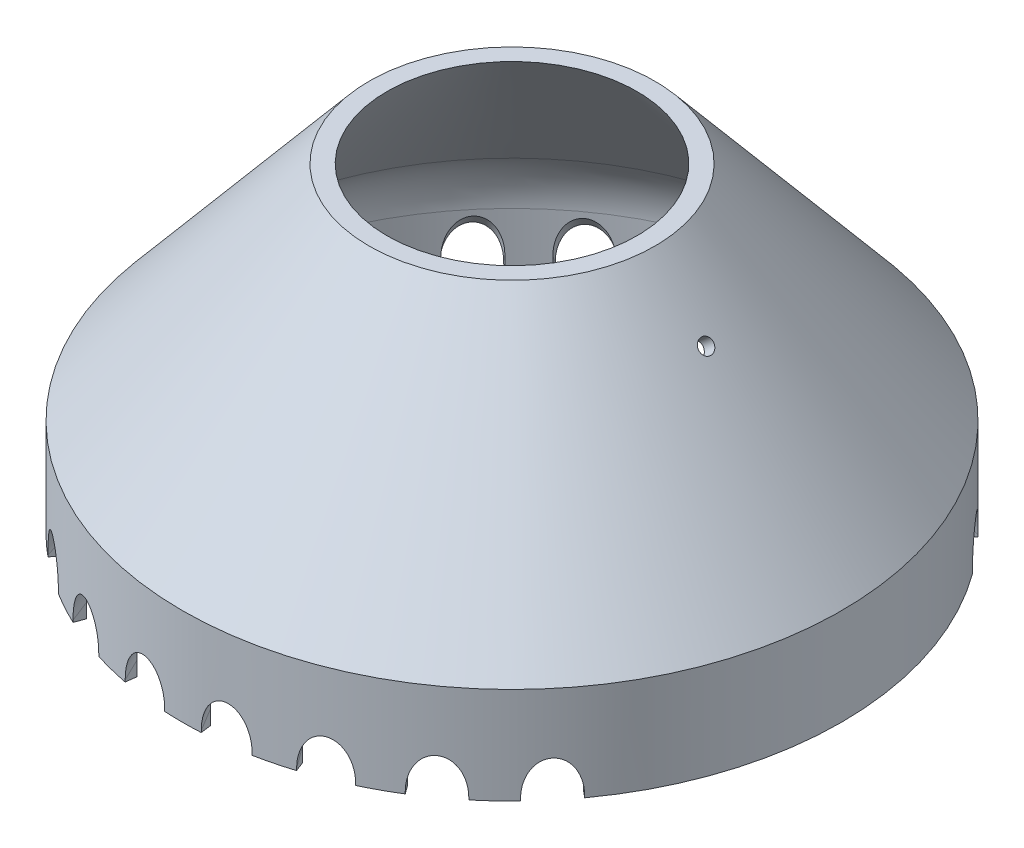
from build123d import *

# Parameters (mm, degrees)
SUPPORT_START                    = -0.012368
SKETCH4_R                        = 0.80645
SUPPORT_HOLE_1_DEPTH             = 1.512368
SUPPORT_HOLE_2_REACH             = 72.738
SKETCH3_R                        = 0.80645
SUPPORT_HOLE_2_DIRECTION_2_REACH = 72.738
TURN_TOOL_CHANNEL_REACH          = 67.392
CRVPATTERN2_COUNT                = 8
CRVPATTERN2_ANGLE                = 100
MIRROR1_COPY_1_REACH             = 67.392
MIRROR1_COPY_2_REACH             = 67.392
MIRROR1_COPY_3_REACH             = 67.392
MIRROR1_COPY_4_REACH             = 67.392
MIRROR1_COPY_5_REACH             = 67.392
MIRROR1_COPY_6_REACH             = 67.392
MIRROR1_COPY_7_REACH             = 67.392


with BuildPart() as part:
    # Cone Cross Section → Revolve1 (revolve)
    with BuildSketch(Plane(origin=(0, 0, 0), x_dir=(1, 0, 0), z_dir=(0, 0, -1)), mode=Mode.PRIVATE) as revolve1_sk:
        with BuildLine():
            Line((13.718550028, 0), (32.660444431, 22.574070706))
            ThreePointArc((32.660444431, 22.574070706), (34.396926208, 25.581745369), (35, 29.001946803))
            Line((35, 29.001946803), (35, 35))
            Line((35, 35), (36.149066665, 35))
            Line((36.149066665, 35), (36.149066665, 24.398063045))
            Line((36.149066665, 24.398063045), (15.676660962, 0))
            Line((15.676660962, 0), (13.718550028, 0))
        make_face()
    revolve(revolve1_sk.sketch.rotate(Axis((0, 0, 0), (0, -1, 0)), 90), axis=Axis((0, 0, 0), (0, -1, 0)))

    # Sketch4 → Support Hole 1 (cut)
    with BuildSketch(Plane(origin=(-8.05037562, 6.755067214, 0), x_dir=(0, 0, 1), z_dir=(-0.766044443118977, 0.6427876096865406, 0)).offset(SUPPORT_START)):
        with Locations(Location((0, -18.818113981, 0), (0, 0, 222.025362507))):
            Circle(SKETCH4_R)
    extrude(amount=SUPPORT_HOLE_1_DEPTH, mode=Mode.SUBTRACT)

    # Support Hole 2: up to this cone (the profile starts outside it)
    support_hole_2_end = Plane(origin=(0, -7.660444, 0), z_dir=(0, -1, 0)).offset(-24.009574281) * Cone(1e-06, 98.505262978, 117.394000044, align=(Align.CENTER, Align.CENTER, Align.MIN), mode=Mode.PRIVATE)
    # Sketch3 → Support Hole 2 (cut, up to the surface)
    with BuildSketch(Plane(origin=(8.05037562, 6.755067214, 0), x_dir=(0, 0, 1), z_dir=(-0.766044443118977, -0.6427876096865406, 0)), mode=Mode.PRIVATE) as support_hole_2_sk1:
        with Locations(Location((0, -18.818113981, 0), (0, 0, 222.025362507))):
            Circle(SKETCH3_R)
    support_hole_2_tool1 = extrude(support_hole_2_sk1.sketch, amount=SUPPORT_HOLE_2_REACH, mode=Mode.PRIVATE) - support_hole_2_end
    add(support_hole_2_tool1.solids().sort_by_distance((20.146426, -7.660444, 0))[0], mode=Mode.SUBTRACT)

    # Support Hole 2 direction 2: up to this cone (the profile starts inside it)
    support_hole_2_direction_2_end = Plane(origin=(0, -7.660444, 0), z_dir=(0, -1, 0)).offset(-26.343160021) * Cone(1e-06, 102.106424075, 121.685696718, align=(Align.CENTER, Align.CENTER, Align.MIN), mode=Mode.PRIVATE)
    # Sketch3 → Support Hole 2 direction 2 (cut, up to the surface)
    with BuildSketch(Plane(origin=(8.05037562, 6.755067214, 0), x_dir=(0, 0, 1), z_dir=(-0.766044443118977, -0.6427876096865406, 0)), mode=Mode.PRIVATE) as support_hole_2_direction_2_sk1:
        with Locations(Location((0, -18.818113981, 0), (0, 0, 222.025362507))):
            Circle(SKETCH3_R)
    support_hole_2_direction_2_tool1 = extrude(support_hole_2_direction_2_sk1.sketch, amount=-SUPPORT_HOLE_2_DIRECTION_2_REACH, mode=Mode.PRIVATE) & support_hole_2_direction_2_end
    add(support_hole_2_direction_2_tool1.solids().sort_by_distance((20.146426, -7.660444, 0))[0], mode=Mode.SUBTRACT)


with BuildPart() as support_hole_2_kept_piece:
    # of the separate pieces the step leaves, the one the design keeps (support_hole_2_pieces_kept)
    add(part.part.solids().sort_by_distance((0, 0, 13.718550028))[0])

    # Sketch5 → Turn Tool Channel (cut, up to next)
    with BuildSketch(Plane(origin=(7.788900643, -12.117378316, 6.535663657), x_dir=(0.8703668320896414, 0.43338422313512226, -0.2337513480940991), z_dir=(-0.4924038765061076, 0.7660444431189767, -0.413175911166533)), mode=Mode.PRIVATE) as turn_tool_channel_sk1:
        with BuildLine():
            Line((1.699455866, -5.569482092), (-1.671674945, -1.876857408))
            Line((-1.671674945, -1.876857408), (2.020949739, 1.494273403))
            Line((2.020949739, 1.494273403), (5.39208055, -2.198351282))
            ThreePointArc((5.39208055, -2.198351282), (5.231333613, -5.730229029), (1.699455866, -5.569482092))
        make_face()
    turn_tool_channel_tool1 = extrude(turn_tool_channel_sk1.sketch, amount=-TURN_TOOL_CHANNEL_REACH, mode=Mode.PRIVATE) & support_hole_2_kept_piece.part
    turn_tool_channel = turn_tool_channel_tool1.solids().sort_by_distance((9.997192, -9.69849, 8.38864))[0]
    add(turn_tool_channel, mode=Mode.SUBTRACT)

    # CrvPattern2: Turn Tool Channel ×8 about axis
    crvpattern2_axis = Axis((0, -10.826005784, 0), (0, -1, 0))
    for i in range(1, CRVPATTERN2_COUNT):
        add(turn_tool_channel.rotate(crvpattern2_axis, i * CRVPATTERN2_ANGLE / (CRVPATTERN2_COUNT - 1)), mode=Mode.SUBTRACT)

    # Mirror1: Turn Tool Channel across plane
    add(turn_tool_channel.mirror(Plane.XY), mode=Mode.SUBTRACT)

    # Mirror1 copy 1 sketch → Mirror1 copy 1 (cut, up to next)
    with BuildSketch(Plane(origin=(5.935323342, -12.117378316, -8.255532054), x_dir=(0.9011326020275271, 0.43338422313512226, 0.011753667541032992), z_dir=(-0.37522319974544693, 0.7660444431189767, 0.5219036899077504)), mode=Mode.PRIVATE) as mirror1_copy_1_sk1:
        with BuildLine():
            Line((1.699455866, 5.569482092), (-1.671674945, 1.876857408))
            Line((-1.671674945, 1.876857408), (2.020949739, -1.494273403))
            Line((2.020949739, -1.494273403), (5.39208055, 2.198351282))
            ThreePointArc((5.39208055, 2.198351282), (5.231333613, 5.730229029), (1.699455866, 5.569482092))
        make_face()
    mirror1_copy_1_tool1 = extrude(mirror1_copy_1_sk1.sketch, amount=-MIRROR1_COPY_1_REACH, mode=Mode.PRIVATE) & support_hole_2_kept_piece.part
    add(mirror1_copy_1_tool1.solids().sort_by_distance((7.618092717, -9.69849, -10.596121568))[0], mode=Mode.SUBTRACT)

    # Mirror1 copy 2 sketch → Mirror1 copy 2 (cut, up to next)
    with BuildSketch(Plane(origin=(3.714673431, -12.117378316, -9.464833541), x_dir=(0.8761674409211258, 0.43338422313512226, -0.21097092360629302), z_dir=(-0.2348366837729102, 0.7660444431189767, 0.5983541118109569)), mode=Mode.PRIVATE) as mirror1_copy_2_sk1:
        with BuildLine():
            Line((1.699455866, 5.569482092), (-1.671674945, 1.876857408))
            Line((-1.671674945, 1.876857408), (2.020949739, -1.494273403))
            Line((2.020949739, -1.494273403), (5.39208055, 2.198351282))
            ThreePointArc((5.39208055, 2.198351282), (5.231333613, 5.730229029), (1.699455866, 5.569482092))
        make_face()
    mirror1_copy_2_tool1 = extrude(mirror1_copy_2_sk1.sketch, amount=-MIRROR1_COPY_2_REACH, mode=Mode.PRIVATE) & support_hole_2_kept_piece.part
    add(mirror1_copy_2_tool1.solids().sort_by_distance((4.767849232, -9.69849, -12.148281468))[0], mode=Mode.SUBTRACT)

    # Mirror1 copy 3 sketch → Mirror1 copy 3 (cut, up to next)
    with BuildSketch(Plane(origin=(1.264287953, -12.117378316, -10.088778352), x_dir=(0.7970153298327136, 0.43338422313512226, -0.42064792778429017), z_dir=(-0.07992659268992885, 0.7660444431189767, 0.637799067847794)), mode=Mode.PRIVATE) as mirror1_copy_3_sk1:
        with BuildLine():
            Line((1.699455866, 5.569482092), (-1.671674945, 1.876857408))
            Line((-1.671674945, 1.876857408), (2.020949739, -1.494273403))
            Line((2.020949739, -1.494273403), (5.39208055, 2.198351282))
            ThreePointArc((5.39208055, 2.198351282), (5.231333613, 5.730229029), (1.699455866, 5.569482092))
        make_face()
    mirror1_copy_3_tool1 = extrude(mirror1_copy_3_sk1.sketch, amount=-MIRROR1_COPY_3_REACH, mode=Mode.PRIVATE) & support_hole_2_kept_piece.part
    add(mirror1_copy_3_tool1.solids().sort_by_distance((1.622736074, -9.69849, -12.949125707))[0], mode=Mode.SUBTRACT)

    # Mirror1 copy 4 sketch → Mirror1 copy 4 (cut, up to next)
    with BuildSketch(Plane(origin=(-1.264287953, -12.117378316, -10.088778352), x_dir=(0.6685714649133934, 0.43338422313512226, -0.6043097810238768), z_dir=(0.07992659268992386, 0.7660444431189767, 0.6377990678477947)), mode=Mode.PRIVATE) as mirror1_copy_4_sk1:
        with BuildLine():
            Line((1.699455866, 5.569482092), (-1.671674945, 1.876857408))
            Line((-1.671674945, 1.876857408), (2.020949739, -1.494273403))
            Line((2.020949739, -1.494273403), (5.39208055, 2.198351282))
            ThreePointArc((5.39208055, 2.198351282), (5.231333613, 5.730229029), (1.699455866, 5.569482092))
        make_face()
    mirror1_copy_4_tool1 = extrude(mirror1_copy_4_sk1.sketch, amount=-MIRROR1_COPY_4_REACH, mode=Mode.PRIVATE) & support_hole_2_kept_piece.part
    add(mirror1_copy_4_tool1.solids().sort_by_distance((-1.622735891, -9.69849, -12.94912573))[0], mode=Mode.SUBTRACT)

    # Mirror1 copy 5 sketch → Mirror1 copy 5 (cut, up to next)
    with BuildSketch(Plane(origin=(-3.714673431, -12.117378316, -9.464833541), x_dir=(0.4987795119042271, 0.43338422313512226, -0.7505978374883235), z_dir=(0.23483668377290537, 0.7660444431189767, 0.5983541118109588)), mode=Mode.PRIVATE) as mirror1_copy_5_sk1:
        with BuildLine():
            Line((1.699455866, 5.569482092), (-1.671674945, 1.876857408))
            Line((-1.671674945, 1.876857408), (2.020949739, -1.494273403))
            Line((2.020949739, -1.494273403), (5.39208055, 2.198351282))
            ThreePointArc((5.39208055, 2.198351282), (5.231333613, 5.730229029), (1.699455866, 5.569482092))
        make_face()
    mirror1_copy_5_tool1 = extrude(mirror1_copy_5_sk1.sketch, amount=-MIRROR1_COPY_5_REACH, mode=Mode.PRIVATE) & support_hole_2_kept_piece.part
    add(mirror1_copy_5_tool1.solids().sort_by_distance((-4.767849061, -9.69849, -12.148281535))[0], mode=Mode.SUBTRACT)

    # Mirror1 copy 6 sketch → Mirror1 copy 6 (cut, up to next)
    with BuildSketch(Plane(origin=(-5.935323342, -12.117378316, -8.255532054), x_dir=(0.29814032673223123, 0.43338422313512226, -0.8504648497813211), z_dir=(0.3752231997454428, 0.7660444431189767, 0.5219036899077534)), mode=Mode.PRIVATE) as mirror1_copy_6_sk1:
        with BuildLine():
            Line((1.699455866, 5.569482092), (-1.671674945, 1.876857408))
            Line((-1.671674945, 1.876857408), (2.020949739, -1.494273403))
            Line((2.020949739, -1.494273403), (5.39208055, 2.198351282))
            ThreePointArc((5.39208055, 2.198351282), (5.231333613, 5.730229029), (1.699455866, 5.569482092))
        make_face()
    mirror1_copy_6_tool1 = extrude(mirror1_copy_6_sk1.sketch, amount=-MIRROR1_COPY_6_REACH, mode=Mode.PRIVATE) & support_hole_2_kept_piece.part
    add(mirror1_copy_6_tool1.solids().sort_by_distance((-7.618092567, -9.69849, -10.596121676))[0], mode=Mode.SUBTRACT)

    # Mirror1 copy 7 sketch → Mirror1 copy 7 (cut, up to next)
    with BuildSketch(Plane(origin=(-7.788900643, -12.117378316, -6.535663657), x_dir=(0.07906252558601568, 0.43338422313512226, -0.8977344998302824), z_dir=(0.4924038765061043, 0.7660444431189767, 0.41317591116653696)), mode=Mode.PRIVATE) as mirror1_copy_7_sk1:
        with BuildLine():
            Line((1.699455866, 5.569482092), (-1.671674945, 1.876857408))
            Line((-1.671674945, 1.876857408), (2.020949739, -1.494273403))
            Line((2.020949739, -1.494273403), (5.39208055, 2.198351282))
            ThreePointArc((5.39208055, 2.198351282), (5.231333613, 5.730229029), (1.699455866, 5.569482092))
        make_face()
    mirror1_copy_7_tool1 = extrude(mirror1_copy_7_sk1.sketch, amount=-MIRROR1_COPY_7_REACH, mode=Mode.PRIVATE) & support_hole_2_kept_piece.part
    add(mirror1_copy_7_tool1.solids().sort_by_distance((-9.997191882, -9.69849, -8.388640141))[0], mode=Mode.SUBTRACT)


solid = support_hole_2_kept_piece.part
